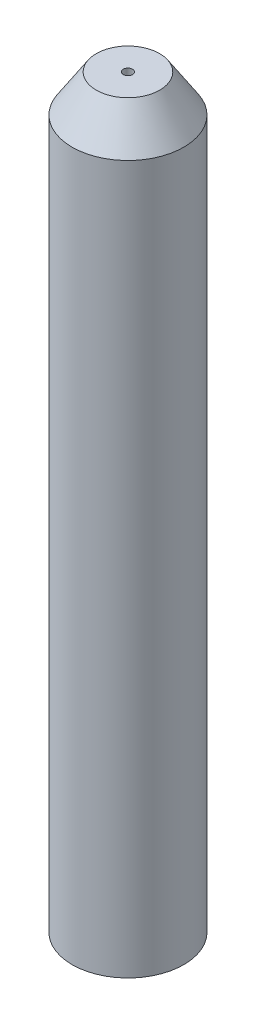
from build123d import *

# Parameters (mm, degrees)
SKETCH1_R           = 3
BOSS_EXTRUDE1_DEPTH = 40
SKETCH2_R           = 0.25
CUT_EXTRUDE1_DEPTH  = 41
CUT_EXTRUDE1_TAPER  = -3
SKETCH4_R           = 0.25
CUT_EXTRUDE3_DEPTH  = 20
CUT_EXTRUDE3_TAPER  = -5
CHAMFER2_SIZE       = 2
CHAMFER2_SIZE2      = 1.298815186


with BuildPart() as part:
    # Sketch1 → Boss-Extrude1 (new body)
    with BuildSketch(Plane(origin=(0, 0, 0), x_dir=(1, 0, 0), z_dir=(0, 1, 0))):
        Circle(SKETCH1_R)
    extrude(amount=BOSS_EXTRUDE1_DEPTH)

    # Sketch2 → Cut-Extrude1 (cut, through all)
    with BuildSketch(Plane(origin=(0, 40, 0), x_dir=(1, 0, 0), z_dir=(0, 1, 0))):
        Circle(SKETCH2_R)
    extrude(amount=-CUT_EXTRUDE1_DEPTH, taper=CUT_EXTRUDE1_TAPER, mode=Mode.SUBTRACT)

    # Sketch4 → Cut-Extrude3 (cut)
    with BuildSketch(Plane(origin=(0, 40, 0), x_dir=(1, 0, 0), z_dir=(0, 1, 0))):
        Circle(SKETCH4_R)
    extrude(amount=-CUT_EXTRUDE3_DEPTH, taper=CUT_EXTRUDE3_TAPER, mode=Mode.SUBTRACT)

    # Chamfer2
    chamfer2_edges = [part.edges().sort_by_distance(p)[0] for p in [
        (-3, 40, 0),
    ]]
    chamfer2_side = [part.faces().sort_by_distance(p)[0] for p in [
        (-3, 20, 0),
    ]]
    chamfer(chamfer2_edges, length=CHAMFER2_SIZE, length2=CHAMFER2_SIZE2, reference=chamfer2_side[0])


solid = part.part
